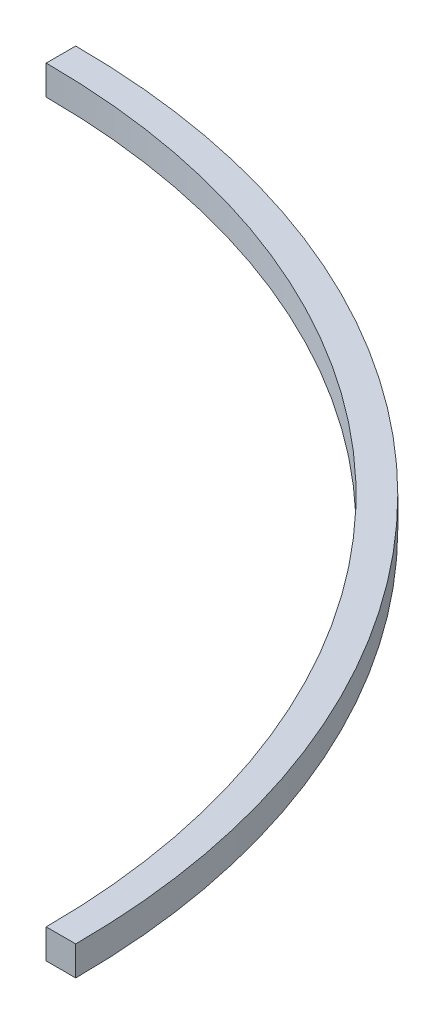
from build123d import *

# Parameters (mm, degrees)
BOSS_EXTRUDE1_DEPTH = 3


with BuildPart() as part:
    # Sketch1 → Boss-Extrude1 (new body)
    with BuildSketch(Plane(origin=(0, 0, 0), x_dir=(1, 0, 0), z_dir=(0, 1, 0))):
        with BuildLine():
            Line((0, 79), (0, 76))
            ThreePointArc((0, 76), (53.74011537, 53.74011537), (76, 0))
            Line((76, 0), (79, 0))
            ThreePointArc((79, 0), (55.861435714, 55.861435714), (0, 79))
        make_face()
    extrude(amount=BOSS_EXTRUDE1_DEPTH)


solid = part.part
